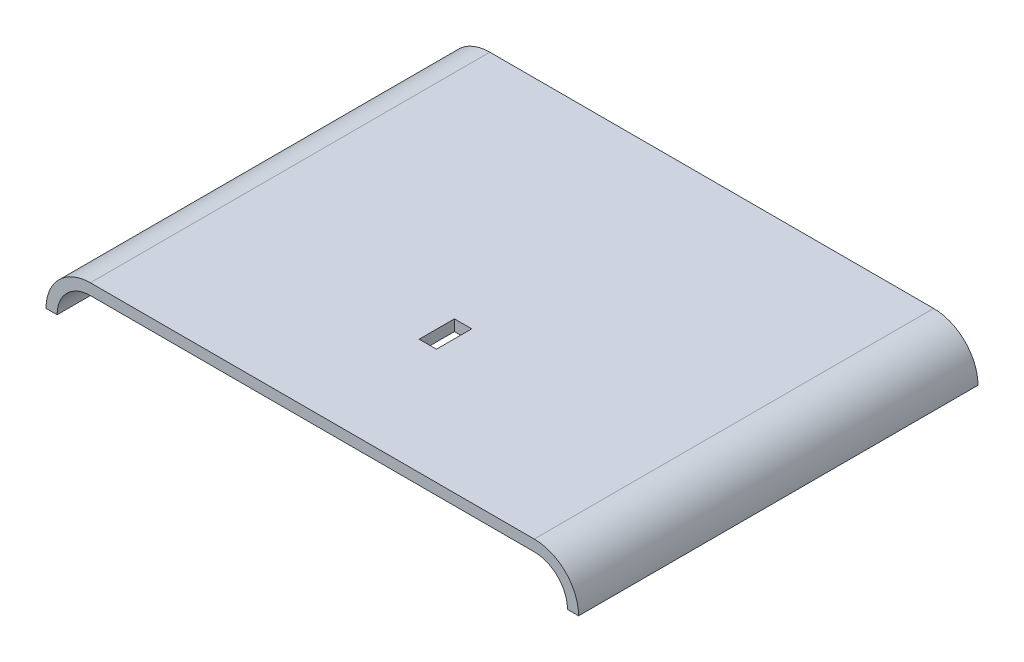
from build123d import *

# Parameters (mm, degrees)
EXTRUDE_THIN1_DEPTH = 457.2
SKETCH5_W           = 19.812
SKETCH5_H           = 40.386
CUT_EXTRUDE1_DEPTH  = 51.8


with BuildPart() as part:
    # Sketch1 → Extrude-Thin1 (new body)
    with BuildSketch(Plane.XY):
        with BuildLine():
            Line((0, 0), (254, 0))
            ThreePointArc((254, 0), (289.921024484, -14.878975516), (304.8, -50.8))
            Line((304.8, -50.8), (292.1, -50.8))
            ThreePointArc((292.1, -50.8), (280.940768363, -23.859231637), (254, -12.7))
            Line((254, -12.7), (0, -12.7))
            Line((0, -12.7), (0, 0))
        make_face()
    extrude_thin1 = extrude(amount=EXTRUDE_THIN1_DEPTH)

    # Mirror1: Extrude-Thin1 across plane
    add(extrude_thin1.mirror(Plane(origin=(0, -12.7, 457.2), x_dir=(0, 0, 1), z_dir=(-1, 0, 0))))

    # Sketch5 → Cut-Extrude1 (cut, through all)
    with BuildSketch(Plane(origin=(0, 0, 0), x_dir=(1, 0, 0), z_dir=(0, 1, 0))):
        with Locations((0, -304.8)):
            Rectangle(SKETCH5_W, SKETCH5_H)
    extrude(amount=-CUT_EXTRUDE1_DEPTH, mode=Mode.SUBTRACT)


solid = part.part
